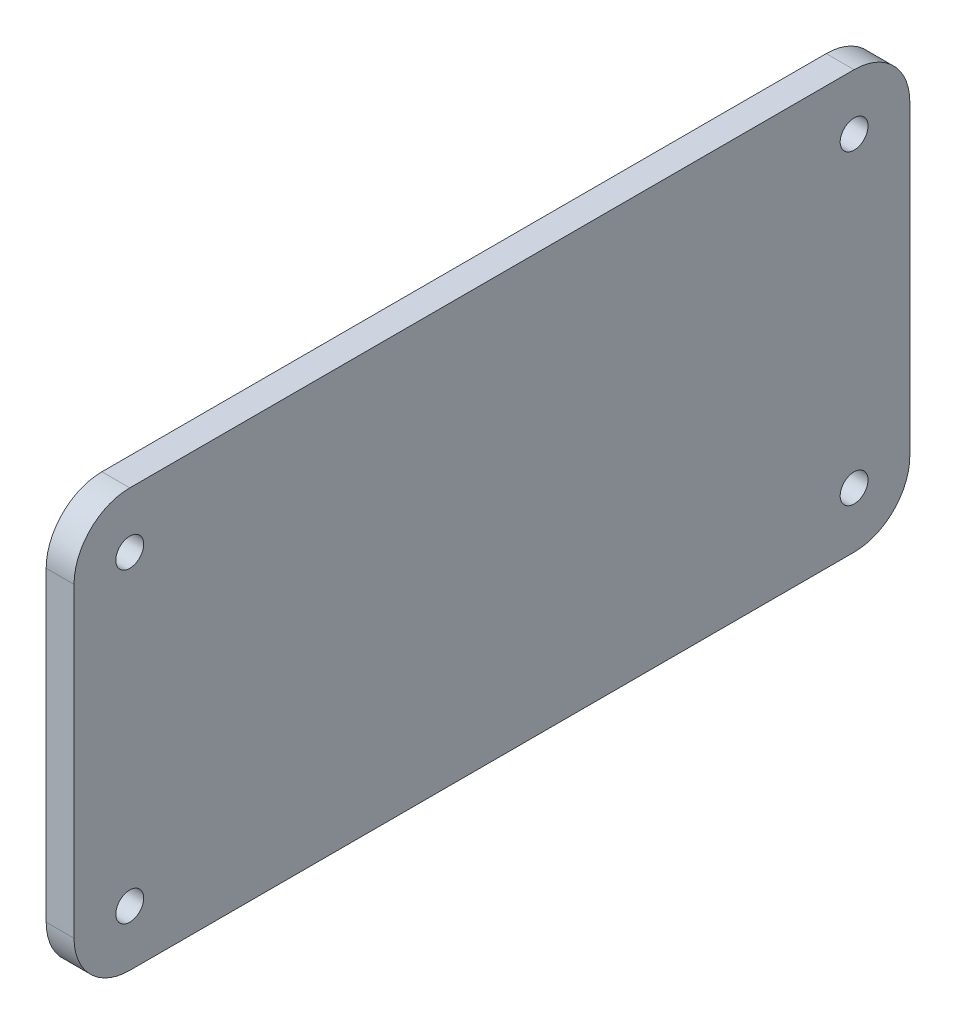
from build123d import *

# Parameters (mm, degrees)
SKETCH1_R           = 2.5
BOSS_EXTRUDE1_DEPTH = 5


with BuildPart() as part:
    # Sketch1 → Boss-Extrude1 (new body)
    with BuildSketch(Plane(origin=(0, 0, 0), x_dir=(0, 0, -1), z_dir=(1, 0, 0))):
        with BuildLine():
            Line((-65, 37.5), (65, 37.5))
            ThreePointArc((65, 37.5), (72.071067812, 34.571067812), (75, 27.5))
            Line((75, 27.5), (75, -27.5))
            ThreePointArc((75, -27.5), (72.071067812, -34.571067812), (65, -37.5))
            Line((65, -37.5), (-65, -37.5))
            ThreePointArc((-65, -37.5), (-72.071067812, -34.571067812), (-75, -27.5))
            Line((-75, -27.5), (-75, 27.5))
            ThreePointArc((-75, 27.5), (-72.071067812, 34.571067812), (-65, 37.5))
        make_face()
        with Locations((-65, 27.5)):
            Circle(SKETCH1_R, mode=Mode.SUBTRACT)
        with Locations((65, 27.5)):
            Circle(SKETCH1_R, mode=Mode.SUBTRACT)
        with Locations((65, -27.5)):
            Circle(SKETCH1_R, mode=Mode.SUBTRACT)
        with Locations((-65, -27.5)):
            Circle(SKETCH1_R, mode=Mode.SUBTRACT)
    extrude(amount=BOSS_EXTRUDE1_DEPTH)


solid = part.part
